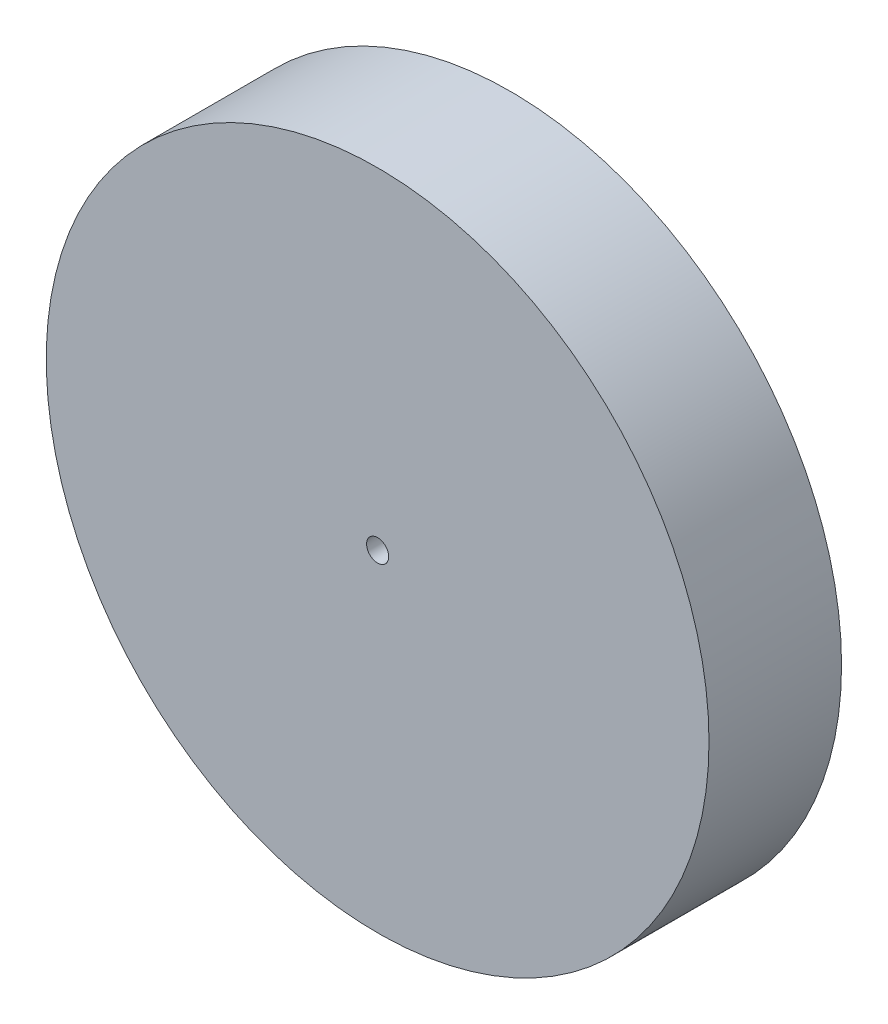
from build123d import *

# Parameters (mm, degrees)
SKETCH1_R           = 75
BOSS_EXTRUDE1_DEPTH = 30
SKETCH2_R           = 2.5
CUT_EXTRUDE1_DEPTH  = 31
SHELL1_T            = -10


with BuildPart() as part:
    # Sketch1 → Boss-Extrude1 (new body)
    with BuildSketch(Plane.XY):
        Circle(SKETCH1_R)
    extrude(amount=BOSS_EXTRUDE1_DEPTH)

    # Sketch2 → Cut-Extrude1 (cut, through all)
    with BuildSketch(Plane(origin=(0, 0, 0), x_dir=(-1, 0, 0), z_dir=(0, 0, -1))):
        Circle(SKETCH2_R)
    extrude(amount=-CUT_EXTRUDE1_DEPTH, mode=Mode.SUBTRACT)

    # Shell1
    shell1_openings = [part.faces().sort_by_distance(p)[0] for p in [
        (-2.5, 0, 0),
    ]]
    offset(amount=SHELL1_T, openings=shell1_openings, kind=Kind.INTERSECTION)


solid = part.part
